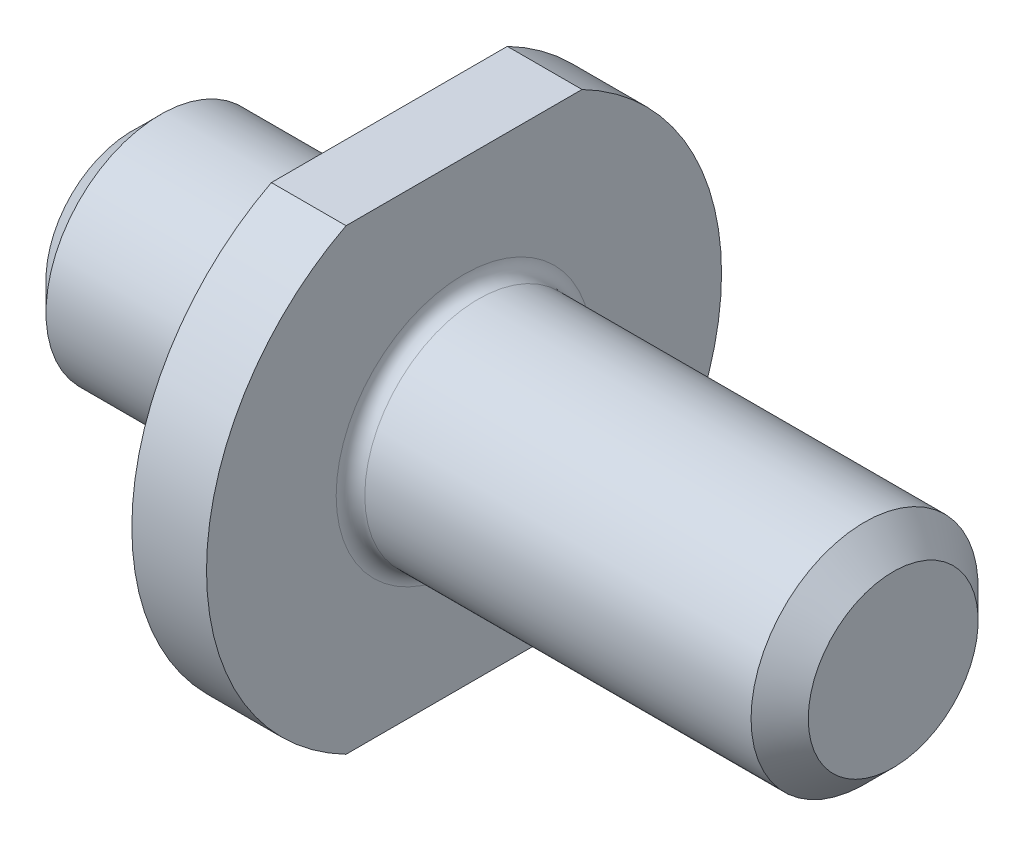
from build123d import *

# Parameters (mm, degrees)
CHAMFER1_SIZE           = 1
FILLET1_R               = 0.5
SKETCH2_OUTSIDE_W       = 27.366
SKETCH2_OUTSIDE_H       = 27.366
SKETCH2_OUTSIDE_W_2     = 26.756004186
SKETCH2_OUTSIDE_H_2     = 16
CUT_EXTRUDE1_DEPTH      = 18.61
CUT_EXTRUDE1_DEPTH_BACK = 10


with BuildPart() as part:
    # Sketch1 → Revolve1 (revolve)
    with BuildSketch(Plane.XY):
        Polygon((0, 4), (0, 9), (2.61, 9), (2.61, 3.96875), (17.61, 3.96875), (17.61, 0), (-9, 0), (-9, 4), align=None)
    revolve(axis=Axis((-38.174026976, 0, 0), (1, 0, 0)))

    # Chamfer1
    chamfer1_edges = [part.edges().sort_by_distance(p)[0] for p in [
        (17.61, -3.96875, 0),
        (-9, -4, 0),
    ]]
    chamfer(chamfer1_edges, length=CHAMFER1_SIZE)

    # Fillet1
    fillet1_edges = [part.edges().sort_by_distance(p)[0] for p in [
        (0, -4, 0),
        (2.61, -3.96875, 0),
    ]]
    fillet(fillet1_edges, radius=FILLET1_R)

    # Sketch2 outside → Cut-Extrude1 (cut, two sides)
    with BuildSketch(Plane(origin=(0, 0, 0), x_dir=(0, 0, -1), z_dir=(1, 0, 0))) as cut_extrude1_sk:
        Rectangle(SKETCH2_OUTSIDE_W, SKETCH2_OUTSIDE_H)
        Rectangle(SKETCH2_OUTSIDE_W_2, SKETCH2_OUTSIDE_H_2, mode=Mode.SUBTRACT)
    extrude(amount=CUT_EXTRUDE1_DEPTH, mode=Mode.SUBTRACT)
    extrude(cut_extrude1_sk.sketch, amount=-CUT_EXTRUDE1_DEPTH_BACK, mode=Mode.SUBTRACT)


solid = part.part
